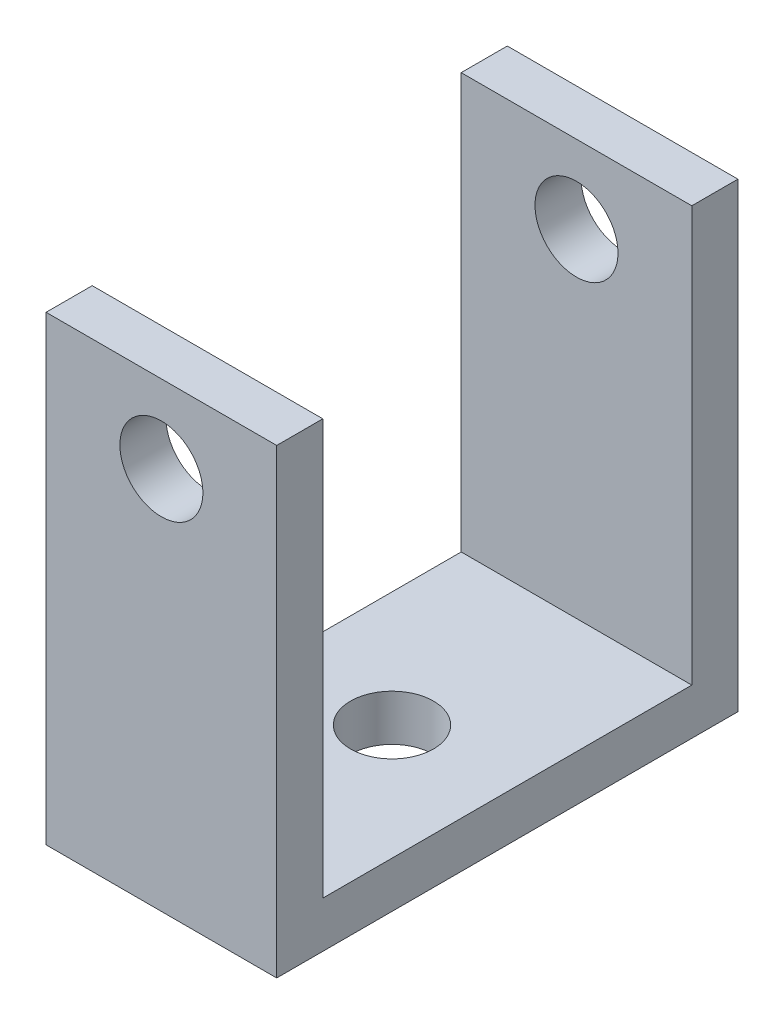
from build123d import *

# Parameters (mm, degrees)
EXTRUDE_THIN1_DEPTH     = 6.35
SKETCH4_R               = 2.286
CUT_EXTRUDE1_DEPTH      = 1
CUT_EXTRUDE1_DEPTH_BACK = 26.4
SKETCH5_R               = 2.286
CUT_EXTRUDE2_DEPTH      = 3.54


with BuildPart() as part:
    # Sketch1 → Extrude-Thin1 (new body, symmetric)
    with BuildSketch(Plane(origin=(0, 0, 0), x_dir=(0, 0, -1), z_dir=(1, 0, 0))):
        Polygon((-12.7, 25.4), (-12.7, 0), (12.7, 0), (12.7, 25.4), (10.16, 25.4), (10.16, 2.54), (-10.16, 2.54), (-10.16, 25.4), align=None)
    extrude(amount=EXTRUDE_THIN1_DEPTH, both=True)

    # Sketch4 → Cut-Extrude1 (cut, two sides)
    with BuildSketch(Plane.XY.offset(12.7)) as cut_extrude1_sk:
        with Locations((0, 21.1074)):
            Circle(SKETCH4_R)
    extrude(amount=CUT_EXTRUDE1_DEPTH, mode=Mode.SUBTRACT)
    extrude(cut_extrude1_sk.sketch, amount=-CUT_EXTRUDE1_DEPTH_BACK, mode=Mode.SUBTRACT)

    # Sketch5 → Cut-Extrude2 (cut, through all)
    with BuildSketch(Plane(origin=(0, 2.54, 0), x_dir=(1, 0, 0), z_dir=(0, 1, 0))):
        Circle(SKETCH5_R)
    extrude(amount=-CUT_EXTRUDE2_DEPTH, mode=Mode.SUBTRACT)


solid = part.part
